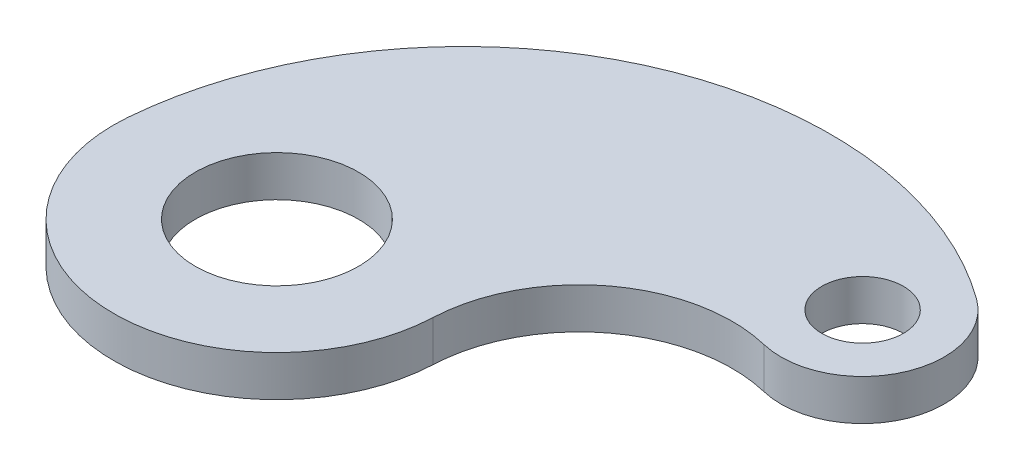
from build123d import *

# Parameters (mm, degrees)
CROQUIS2_R                   = 40
CROQUIS2_R_2                 = 20
SALIENTE_EXTRUIR1_DEPTH      = 10
SALIENTE_EXTRUIR1_DEPTH_BACK = 10


with BuildPart() as part:
    # Croquis2 → Saliente-Extruir1 (new body, two sides)
    with BuildSketch(Plane(origin=(0, 0, 0), x_dir=(1, 0, 0), z_dir=(0, 1, 0))) as saliente_extruir1_sk:
        with BuildLine():
            ThreePointArc((172.469235199, 66.119242389), (218.184271838, 88.238889892), (205.354467187, 137.376853761))
            ThreePointArc((205.354467187, 137.376853761), (24.626451497, 155.299352148), (-79.722697138, 6.655190531))
            ThreePointArc((-79.722697138, 6.655190531), (-5.078826092, -79.838621766), (79.923379849, -3.500479035))
            ThreePointArc((79.923379849, -3.500479035), (109.764419077, 53.152375878), (172.469235199, 66.119242389))
        make_face()
        Circle(CROQUIS2_R, mode=Mode.SUBTRACT)
        with Locations((181.865334795, 105)):
            Circle(CROQUIS2_R_2, mode=Mode.SUBTRACT)
    extrude(amount=SALIENTE_EXTRUIR1_DEPTH)
    extrude(saliente_extruir1_sk.sketch, amount=-SALIENTE_EXTRUIR1_DEPTH_BACK)


solid = part.part
